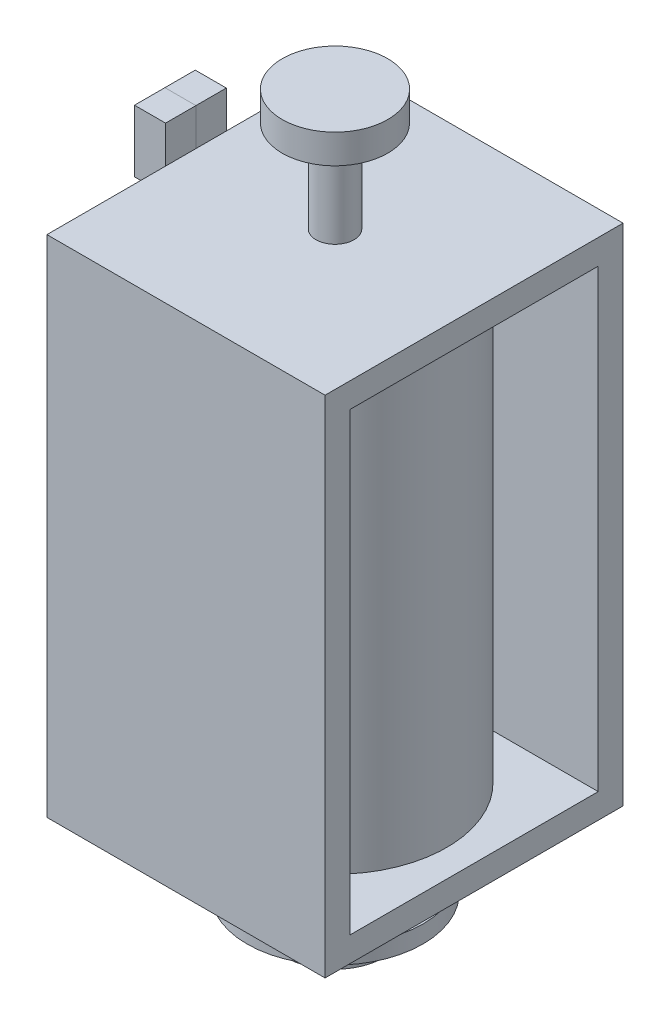
from build123d import *

# Parameters (mm, degrees)
SKETCH3_W            = 12.192
SKETCH3_H            = 20.6502
SKETCH3_W_2          = 10.16
SKETCH3_H_2          = 18.6182
BOSS_EXTRUDE3_DEPTH  = 5.6896
SKETCH2_R            = 4.572
BOSS_EXTRUDE2_DEPTH  = 9.398
SKETCH4_R            = 0.7747
BOSS_EXTRUDE4_DEPTH  = 3.7592
SKETCH5_R            = 2.0066
BOSS_EXTRUDE5_DEPTH  = 4.1656
BOSS_EXTRUDE11_DEPTH = 0.7112
SKETCH7_W            = 1.242870129
SKETCH7_H            = 2.54
BOSS_EXTRUDE12_DEPTH = 1.27
SKETCH7_3_W          = 1.242870129
SKETCH7_3_H          = 2.54
BOSS_EXTRUDE13_DEPTH = 1.27
SKETCH8_R            = 2.159
BOSS_EXTRUDE14_DEPTH = 1.1938


with BuildPart() as part:
    # Sketch3 → Boss-Extrude3 (new, symmetric)
    with BuildSketch(Plane(origin=(0, 0, 0), x_dir=(0, 0, -1), z_dir=(1, 0, 0))):
        Rectangle(SKETCH3_W, SKETCH3_H)
        Rectangle(SKETCH3_W_2, SKETCH3_H_2, mode=Mode.SUBTRACT)
    extrude(amount=BOSS_EXTRUDE3_DEPTH, both=True)

    # Sketch2 → Boss-Extrude2 (add, symmetric)
    with BuildSketch(Plane(origin=(0, 0, 0), x_dir=(1, 0, 0), z_dir=(0, 1, 0))):
        Circle(SKETCH2_R)
    extrude(amount=BOSS_EXTRUDE2_DEPTH, both=True)

    # Sketch5 → Boss-Extrude5 (add)
    with BuildSketch(Plane.XZ.offset(10.3251)):
        Circle(SKETCH5_R)
    extrude(amount=BOSS_EXTRUDE5_DEPTH)

    # Sketch6 → Boss-Extrude11 (add)
    with BuildSketch(Plane.XZ.offset(12.5095)):
        with BuildLine():
            Line((-2.667, -2.409287407), (-1.488996466, -1.345114524))
            ThreePointArc((-1.488996466, -1.345114524), (0, 2.0066), (1.488996466, -1.345114524))
            Line((1.488996466, -1.345114524), (2.667, -2.409287407))
            ThreePointArc((2.667, -2.409287407), (0, 3.5941), (-2.667, -2.409287407))
        make_face()
    extrude(amount=BOSS_EXTRUDE11_DEPTH)


with BuildPart() as body_2:
    # Sketch4 → Boss-Extrude4 (new body)
    with BuildSketch(Plane(origin=(0, 10.3251, 0), x_dir=(1, 0, 0), z_dir=(0, 1, 0))):
        Circle(SKETCH4_R)
    extrude(amount=BOSS_EXTRUDE4_DEPTH)


with BuildPart() as body_3:
    # Sketch7 → Boss-Extrude12 (new body)
    with BuildSketch(Plane.ZY.offset(5.6896)):
        with Locations((-0.621435065, 10.5791)):
            Rectangle(SKETCH7_W, SKETCH7_H)
    extrude(amount=BOSS_EXTRUDE12_DEPTH)


with BuildPart() as body_4:
    # Sketch7_3 → Boss-Extrude13 (new body)
    with BuildSketch(Plane.ZY.offset(5.6896)):
        with Locations((0.621435065, 10.5791)):
            Rectangle(SKETCH7_3_W, SKETCH7_3_H)
    extrude(amount=BOSS_EXTRUDE13_DEPTH)


with BuildPart() as body_5:
    # Sketch8 → Boss-Extrude14 (new body)
    with BuildSketch(Plane(origin=(0, 14.0843, 0), x_dir=(1, 0, 0), z_dir=(0, 1, 0))):
        Circle(SKETCH8_R)
    extrude(amount=BOSS_EXTRUDE14_DEPTH)


solid = Compound([part.part, body_2.part, body_3.part, body_4.part, body_5.part])
